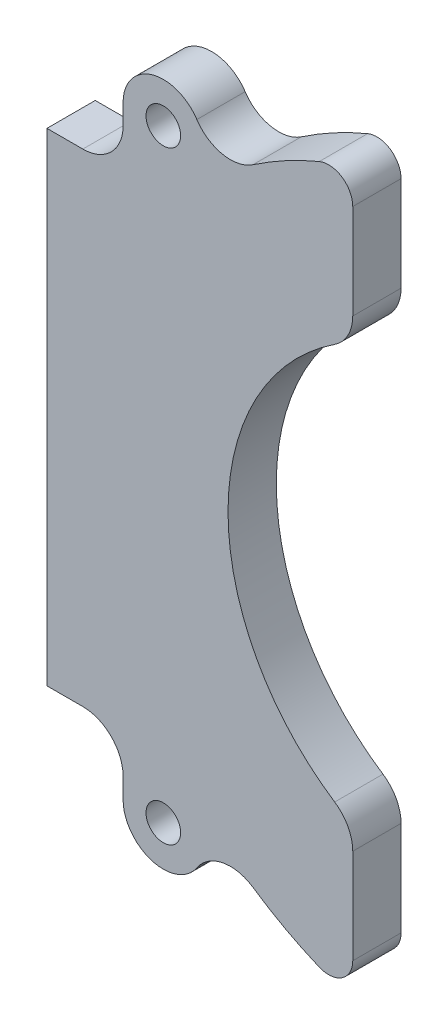
from build123d import *

# Parameters (mm, degrees)
SKETCH_1_R          = 2.15
EXTRUDE_1_DEPTH     = 6
CUT_EXTRUDE_1_DEPTH = 10
FILLET_1_R          = 5
FILLET_2_R          = 3


with BuildPart() as part:
    # 草图1 → 凸台-拉伸1 (new body)
    with BuildSketch(Plane.XY):
        with BuildLine():
            Line((-52, 30), (-52, 8.75))
            Line((-52, 8.75), (-52, -8.75))
            Line((-52, -8.75), (-52, -30))
            Line((-52, -30), (-47.54, -30))
            ThreePointArc((-47.54, -30), (-44.004466094, -31.464466094), (-42.54, -35))
            Line((-42.54, -35), (-42.54, -37.5))
            ThreePointArc((-42.54, -37.5), (-38.982425028, -42.287422066), (-33.372235985, -40.262198963))
            ThreePointArc((-33.372235985, -40.262198963), (-30.171244586, -38.118753147), (-26.396349665, -38.887436588))
            ThreePointArc((-26.396349665, -38.887436588), (0, -47), (26.396349665, -38.887436588))
            ThreePointArc((26.396349665, -38.887436588), (30.171244586, -38.118753147), (33.372235985, -40.262198963))
            ThreePointArc((33.372235985, -40.262198963), (38.674773042, -42.369526686), (42.499484755, -38.135225128))
            Line((42.499484755, -38.135225128), (46.619156699, -5.971116201))
            ThreePointArc((46.619156699, -5.971116201), (47, 0), (46.619156699, 5.971116201))
            Line((46.619156699, 5.971116201), (42.499484755, 38.135225128))
            ThreePointArc((42.499484755, 38.135225128), (38.674773042, 42.369526686), (33.372235985, 40.262198963))
            ThreePointArc((33.372235985, 40.262198963), (30.171244586, 38.118753147), (26.396349665, 38.887436588))
            ThreePointArc((26.396349665, 38.887436588), (0, 47), (-26.396349665, 38.887436588))
            ThreePointArc((-26.396349665, 38.887436588), (-30.171244586, 38.118753147), (-33.372235985, 40.262198963))
            ThreePointArc((-33.372235985, 40.262198963), (-38.982425028, 42.287422066), (-42.54, 37.5))
            Line((-42.54, 37.5), (-42.54, 35))
            ThreePointArc((-42.54, 35), (-44.004466094, 31.464466094), (-47.54, 30))
            Line((-47.54, 30), (-52, 30))
        make_face()
        with Locations((-37.54, -37.5)):
            Circle(SKETCH_1_R, mode=Mode.SUBTRACT)
        with Locations((37.54, -37.5)):
            Circle(SKETCH_1_R, mode=Mode.SUBTRACT)
        with Locations((-37.54, 37.5)):
            Circle(SKETCH_1_R, mode=Mode.SUBTRACT)
        with Locations((37.54, 37.5)):
            Circle(SKETCH_1_R, mode=Mode.SUBTRACT)
    extrude(amount=EXTRUDE_1_DEPTH)

    # 草图2 → 切除-拉伸1 (cut)
    with BuildSketch(Plane.XY.offset(6)):
        with BuildLine():
            Line((-14, 44.866468548), (-14, 25.966324345))
            ThreePointArc((-14, 25.966324345), (-29.5, 0), (-14, -25.966324345))
            Line((-14, -25.966324345), (-14, -44.866468548))
            ThreePointArc((-14, -44.866468548), (6.881466199, -46.493498717), (26.396349665, -38.887436588))
            ThreePointArc((26.396349665, -38.887436588), (30.171244586, -38.118753147), (33.372235985, -40.262198963))
            ThreePointArc((33.372235985, -40.262198963), (38.674773042, -42.369526686), (42.499484755, -38.135225128))
            Line((42.499484755, -38.135225128), (46.619156699, -5.971116201))
            ThreePointArc((46.619156699, -5.971116201), (47, 0), (46.619156699, 5.971116201))
            Line((46.619156699, 5.971116201), (42.499484755, 38.135225128))
            ThreePointArc((42.499484755, 38.135225128), (38.674773042, 42.369526686), (33.372235985, 40.262198963))
            ThreePointArc((33.372235985, 40.262198963), (30.171244586, 38.118753147), (26.396349665, 38.887436588))
            ThreePointArc((26.396349665, 38.887436588), (6.881466199, 46.493498717), (-14, 44.866468548))
        make_face()
    extrude(amount=-CUT_EXTRUDE_1_DEPTH, mode=Mode.SUBTRACT)

    # 圆角1
    fillet_1_edges = [part.edges().sort_by_distance(p)[0] for p in [
        (-14, -25.966324345, 3),
        (-14, 25.966324345, 3),
    ]]
    fillet(fillet_1_edges, radius=FILLET_1_R)

    # 圆角2
    fillet_2_edges = [part.edges().sort_by_distance(p)[0] for p in [
        (-14, 44.866468548, 3),
        (-14, -44.866468548, 3),
    ]]
    fillet(fillet_2_edges, radius=FILLET_2_R)


solid = part.part
